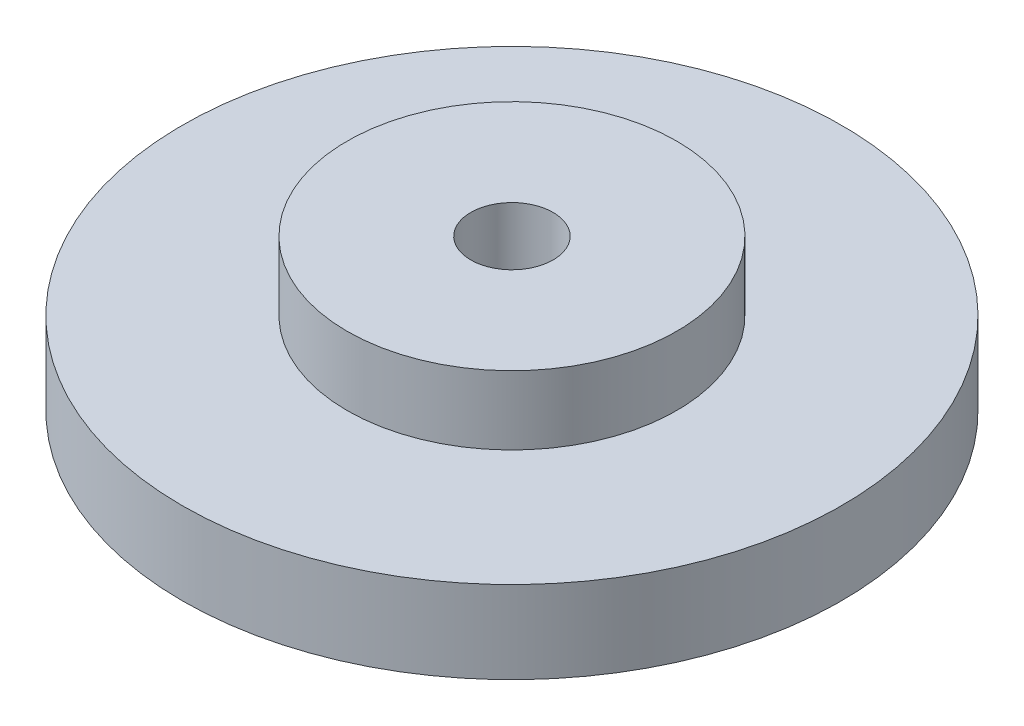
from build123d import *

# Parameters (mm, degrees)
SKETCH1_R           = 48
BOSS_EXTRUDE1_DEPTH = 12
SKETCH2_R           = 24
BOSS_EXTRUDE2_DEPTH = 10
SKETCH3_R           = 6
CUT_EXTRUDE1_DEPTH  = 34
SKETCH4_R           = 4
CUT_EXTRUDE2_DEPTH  = 10


with BuildPart() as part:
    # Sketch1 → Boss-Extrude1 (new body)
    with BuildSketch(Plane(origin=(0, 0, 0), x_dir=(1, 0, 0), z_dir=(0, 1, 0))):
        Circle(SKETCH1_R)
    extrude(amount=BOSS_EXTRUDE1_DEPTH)

    # Sketch2 → Boss-Extrude2 (add)
    with BuildSketch(Plane(origin=(0, 12, 0), x_dir=(1, 0, 0), z_dir=(0, 1, 0))):
        Circle(SKETCH2_R)
    extrude(amount=BOSS_EXTRUDE2_DEPTH)

    # Sketch3 → Cut-Extrude1 (cut)
    with BuildSketch(Plane(origin=(0, 22, 0), x_dir=(1, 0, 0), z_dir=(0, 1, 0))):
        Circle(SKETCH3_R)
    extrude(amount=-CUT_EXTRUDE1_DEPTH, mode=Mode.SUBTRACT)

    # Sketch4 → Cut-Extrude2 (cut)
    with BuildSketch(Plane.XZ):
        with Locations((0, 36)):
            Circle(SKETCH4_R)
        with Locations((31.176914536, 18)):
            Circle(SKETCH4_R)
        with Locations((31.176914536, -18)):
            Circle(SKETCH4_R)
        with Locations((0, -36)):
            Circle(SKETCH4_R)
        with Locations((-31.176914536, -18)):
            Circle(SKETCH4_R)
        with Locations((-31.176914536, 18)):
            Circle(SKETCH4_R)
    extrude(amount=-CUT_EXTRUDE2_DEPTH, mode=Mode.SUBTRACT)


solid = part.part
